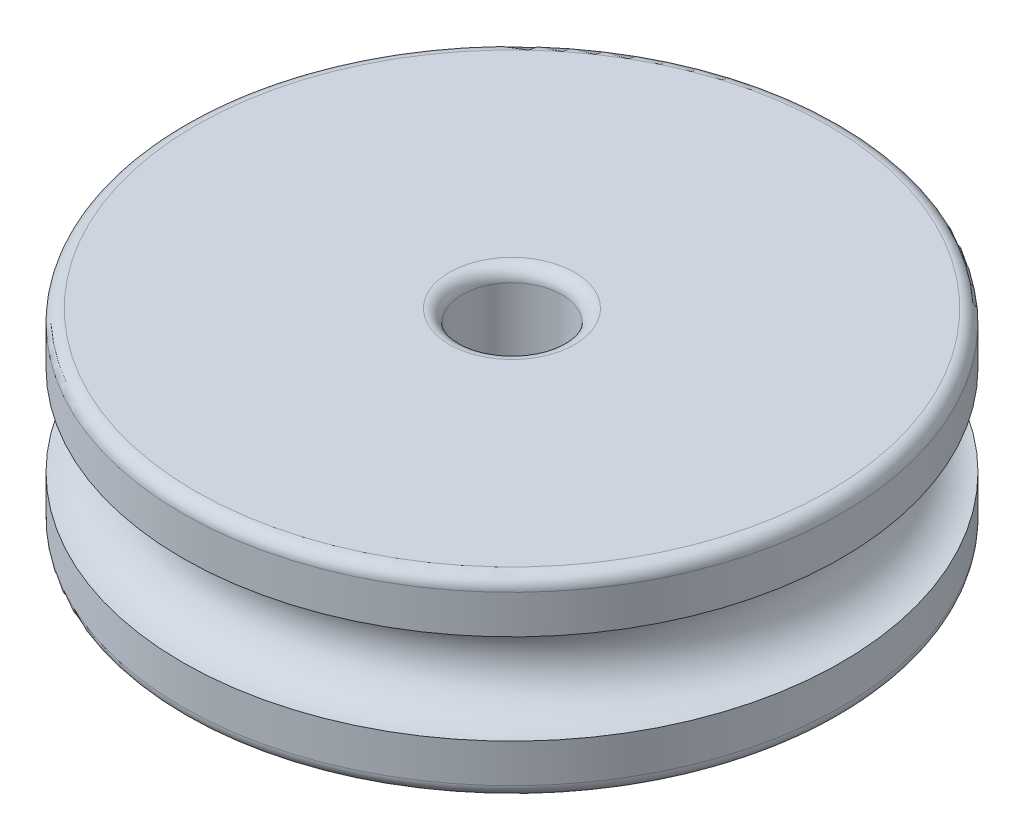
from build123d import *

# Parameters (mm, degrees)
SALIENTE_EXTRUIR1_DEPTH      = 7.5
SALIENTE_EXTRUIR1_DEPTH_BACK = 7.5
CROQUIS1_R                   = 25.58
CROQUIS1_R_2                 = 3.86
CROQUIS2_R                   = 3.505
REDONDEO1_R                  = 1


with BuildPart() as part:
    # Croquis1 → Saliente-Extruir1 (new, two sides: drawn at the far end of the back side and taken through both)
    with BuildSketch(Plane(origin=(0, 0, 0), x_dir=(1, 0, 0), z_dir=(0, 1, 0)).offset(-SALIENTE_EXTRUIR1_DEPTH_BACK)):
        Circle(CROQUIS1_R)
        Circle(CROQUIS1_R_2, mode=Mode.SUBTRACT)
    extrude(amount=SALIENTE_EXTRUIR1_DEPTH + SALIENTE_EXTRUIR1_DEPTH_BACK)

    # Cortar-Barrer1: sweep along a path in Croquis1_4
    with BuildLine(Plane(origin=(0, 0, 0), x_dir=(1, 0, 0), z_dir=(0, 1, 0))) as cortar_barrer1_path:
        CenterArc((0, 0), 25.58, 0, 360)
    # Croquis2 → Cortar-Barrer1 (sweep, cut)
    with BuildSketch(Plane.XY):
        with Locations((-25.58, 0)):
            Circle(CROQUIS2_R)
    sweep(path=cortar_barrer1_path.line, mode=Mode.SUBTRACT)

    # Redondeo1
    redondeo1_edges = [part.edges().sort_by_distance(p)[0] for p in [
        (-25.58, -7.5, 0),
        (-25.58, 7.5, 0),
        (-3.86, 7.5, 0),
        (-3.86, -7.5, 0),
    ]]
    fillet(redondeo1_edges, radius=REDONDEO1_R)


solid = part.part
